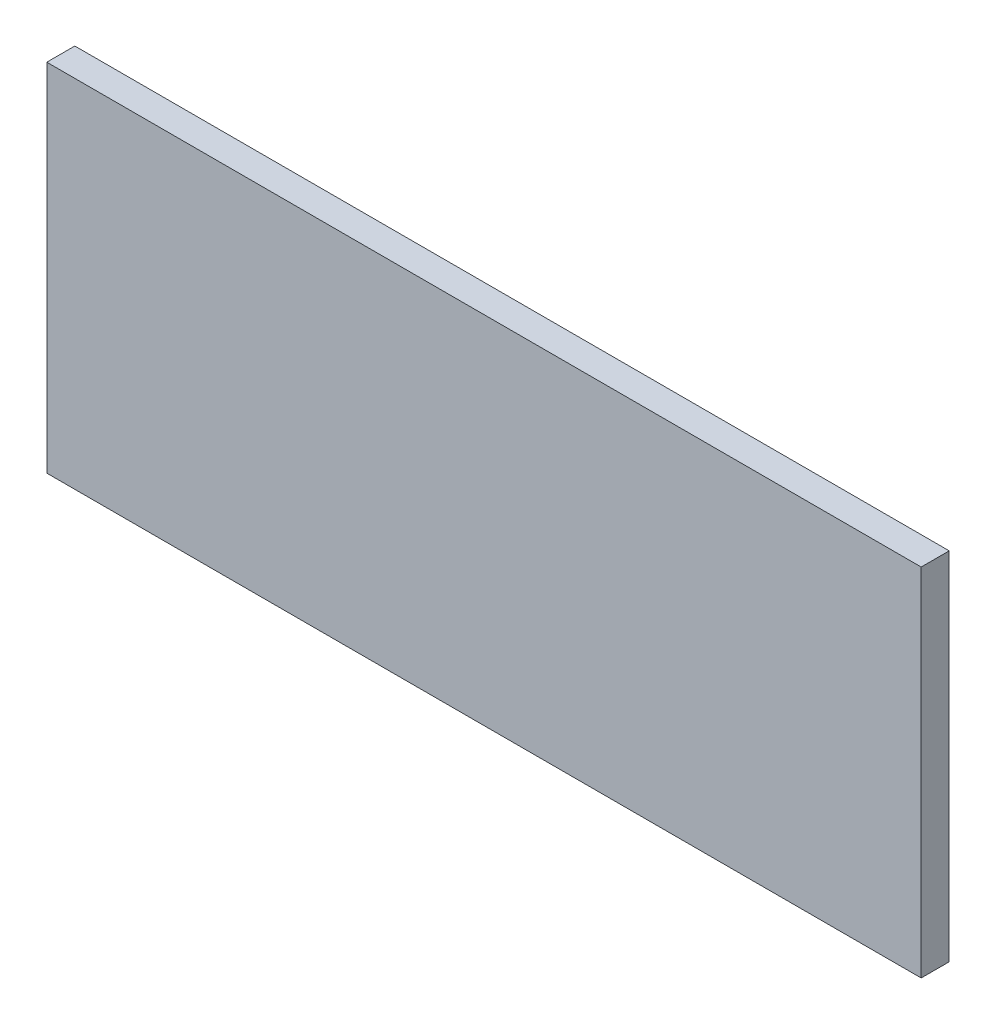
from build123d import *

# Parameters (mm, degrees)
SKETCH2_W           = 312
SKETCH2_H           = 127
BOSS_EXTRUDE1_DEPTH = 10


with BuildPart() as part:
    # Sketch2 → Boss-Extrude1 (new body)
    with BuildSketch(Plane.XY):
        with Locations((-199.778571571, -12.79123525)):
            Rectangle(SKETCH2_W, SKETCH2_H)
    extrude(amount=BOSS_EXTRUDE1_DEPTH)


solid = part.part
